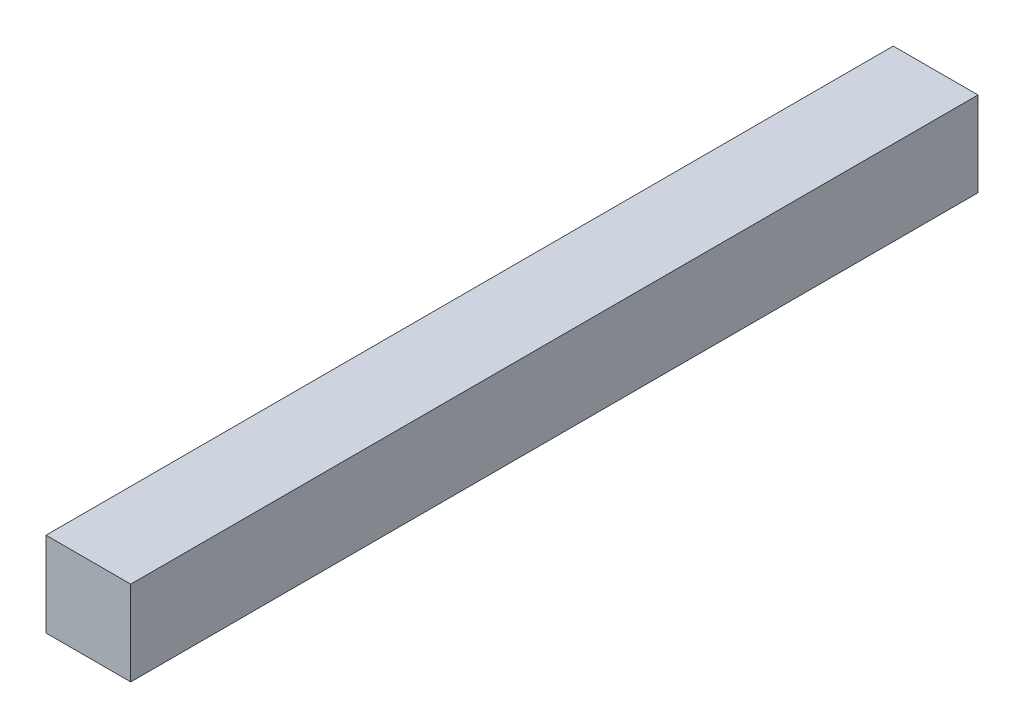
from build123d import *

# Parameters (mm, degrees)
SKETCH1_W           = 30
SKETCH1_H           = 30
BOSS_EXTRUDE1_DEPTH = 300
SKETCH2_R           = 10
CUT_EXTRUDE1_DEPTH  = 10


with BuildPart() as part:
    # Sketch1 → Boss-Extrude1 (new body)
    with BuildSketch(Plane.XY):
        Rectangle(SKETCH1_W, SKETCH1_H)
    extrude(amount=BOSS_EXTRUDE1_DEPTH)

    # Sketch2 → Cut-Extrude1 (cut)
    with BuildSketch(Plane.XZ.offset(15)):
        with Locations((0, 280)):
            Circle(SKETCH2_R)
    extrude(amount=-CUT_EXTRUDE1_DEPTH, mode=Mode.SUBTRACT)


solid = part.part
